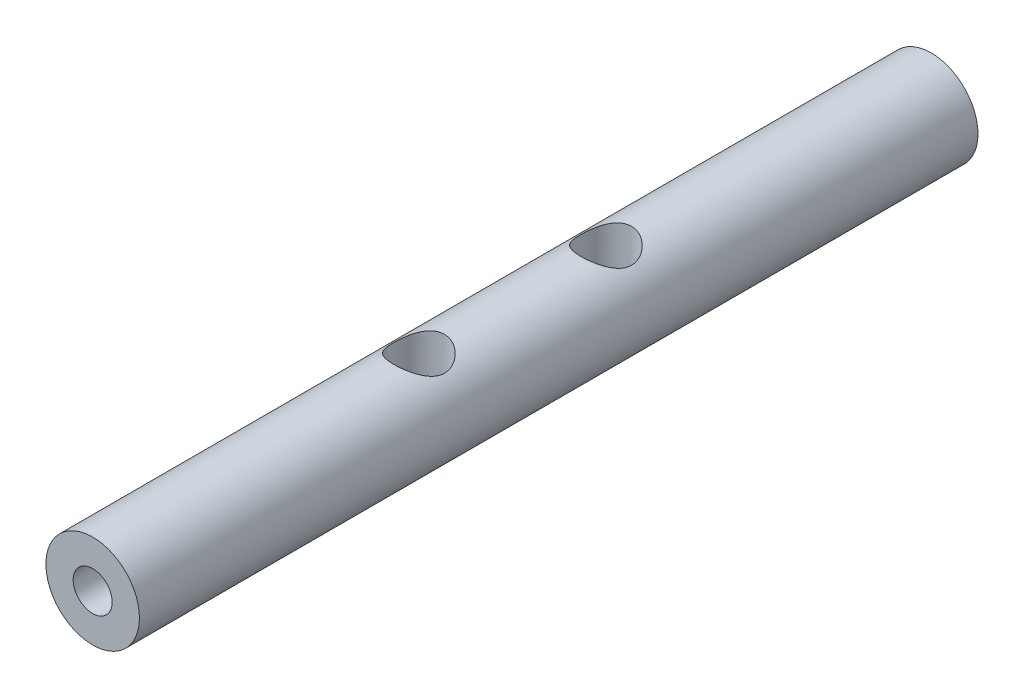
from build123d import *

# Parameters (mm, degrees)
SKETCH_1_R      = 3
EXTRUDE_1_DEPTH = 53.8
M4X0_7_1_D      = 3.3
M4X0_7_1_DEPTH  = 11.5
M4X0_7_1_TIP    = 0.991420021
M3X0_5_2_D      = 2.5
M3X0_5_2_DEPTH  = 8.5
M3X0_5_2_TIP    = 0.751075774


with BuildPart() as part:
    # ｽｹｯﾁ1 → ﾎﾞｽ - 押し出し1 (new body)
    with BuildSketch(Plane.XY):
        Circle(SKETCH_1_R)
    extrude(amount=EXTRUDE_1_DEPTH)

    # M4x0.7 ねじ穴1
    with Locations(Plane(origin=(0.029051092, 2.999859336, 32.9), x_dir=(0.999953112, -0.009683697, 0), z_dir=(0.009683697, 0.999953112, 0))):
        with Locations((0, 0), (0, 12)):
            Hole(M4X0_7_1_D / 2, depth=M4X0_7_1_DEPTH)
            with Locations((0, 0, -(M4X0_7_1_DEPTH + M4X0_7_1_TIP / 2))):  # 118° drill point
                Cone(0, M4X0_7_1_D / 2, M4X0_7_1_TIP, mode=Mode.SUBTRACT)

    # ｽｹｯﾁ7 → M3x0.5 ねじ穴1 (revolve, cut)
    with BuildSketch(Plane(origin=(0, 0, 53.8), x_dir=(0, -1, 0), z_dir=(1, 0, 0))):
        Polygon((0, 0), (0, 9.251075774), (1.25, 8.5), (1.25, 0), align=None)
    revolve(axis=Axis((0, 0, 60.15), (0, 0, -1)), mode=Mode.SUBTRACT)

    # M3x0.5 ねじ穴2
    with Locations(Plane(origin=(0, 0, 0), x_dir=(-1, 0, 0), z_dir=(0, 0, -1))):
        with Locations((0, 0)):
            Hole(M3X0_5_2_D / 2, depth=M3X0_5_2_DEPTH)
            with Locations((0, 0, -(M3X0_5_2_DEPTH + M3X0_5_2_TIP / 2))):  # 118° drill point
                Cone(0, M3X0_5_2_D / 2, M3X0_5_2_TIP, mode=Mode.SUBTRACT)


solid = part.part
